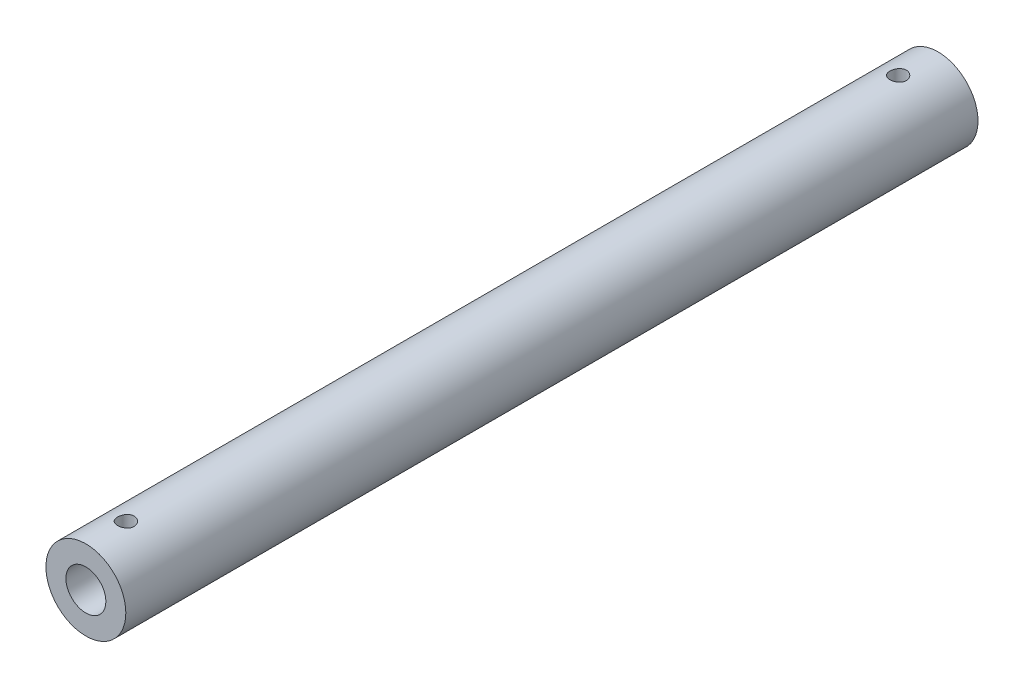
from build123d import *

# Parameters (mm, degrees)
BOSS_EXTRUDE1_DEPTH      = 160
BOSS_EXTRUDE1_DEPTH_BACK = 160
SKETCH1_R                = 15
SKETCH1_R_2              = 7.5
SKETCH2_R                = 3.1
CUT_EXTRUDE1_DEPTH       = 162.400123916


with BuildPart() as part:
    # Sketch1 → Boss-Extrude1 (new, two sides: drawn at the far end of the back side and taken through both)
    with BuildSketch(Plane.XY.offset(-BOSS_EXTRUDE1_DEPTH_BACK)):
        Circle(SKETCH1_R)
        Circle(SKETCH1_R_2, mode=Mode.SUBTRACT)
    extrude(amount=BOSS_EXTRUDE1_DEPTH + BOSS_EXTRUDE1_DEPTH_BACK)

    # Sketch2 → Cut-Extrude1 (cut, through all)
    with BuildSketch(Plane(origin=(0, 0, 0), x_dir=(1, 0, 0), z_dir=(0, 1, 0))):
        with Locations((0, -145)):
            Circle(SKETCH2_R)
    cut_extrude1 = extrude(amount=CUT_EXTRUDE1_DEPTH, mode=Mode.SUBTRACT)

    # Mirror1: Cut-Extrude1 across plane
    add(cut_extrude1.mirror(Plane.XY), mode=Mode.SUBTRACT)


solid = part.part
